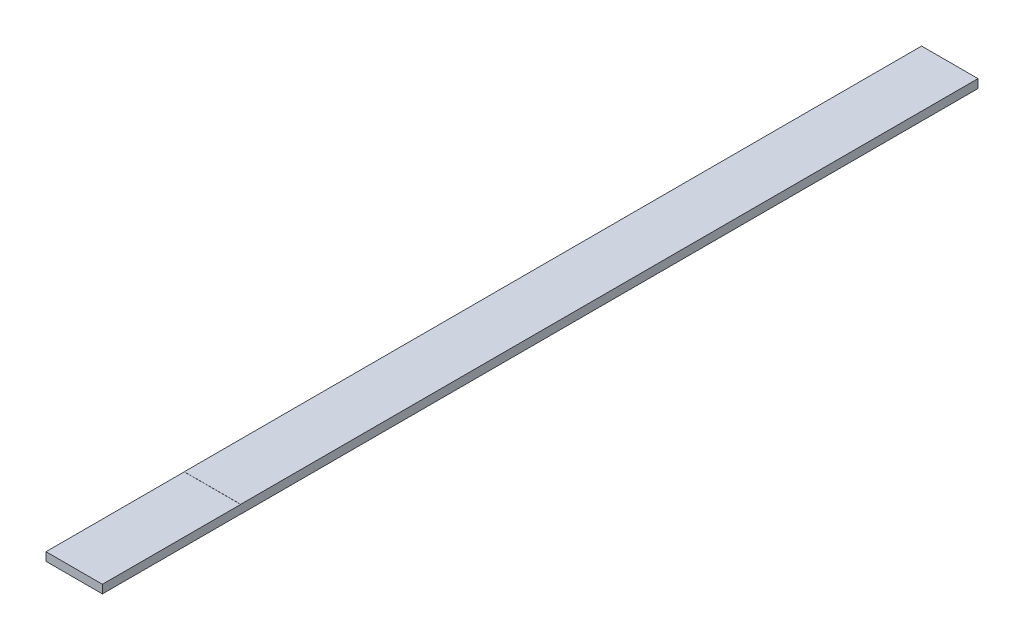
from build123d import *

# Parameters (mm, degrees)
SKETCH2_W           = 36
SKETCH2_H           = 5.5
BOSS_EXTRUDE1_DEPTH = 558.8
SKETCH3_W           = 88.25
SKETCH3_H           = 0.06858
CUT_EXTRUDE1_DEPTH  = 37


with BuildPart() as part:
    # Sketch2 → Boss-Extrude1 (new body)
    with BuildSketch(Plane.XY):
        Rectangle(SKETCH2_W, SKETCH2_H)
    extrude(amount=BOSS_EXTRUDE1_DEPTH)

    # Sketch3 → Cut-Extrude1 (cut, through all)
    with BuildSketch(Plane(origin=(18, 0, 0), x_dir=(0, 0, -1), z_dir=(1, 0, 0))):
        with Locations((-514.675, -2.71571)):
            Rectangle(SKETCH3_W, SKETCH3_H)
        with Locations((-514.675, 2.71571)):
            Rectangle(SKETCH3_W, SKETCH3_H)
    extrude(amount=-CUT_EXTRUDE1_DEPTH, mode=Mode.SUBTRACT)


solid = part.part
